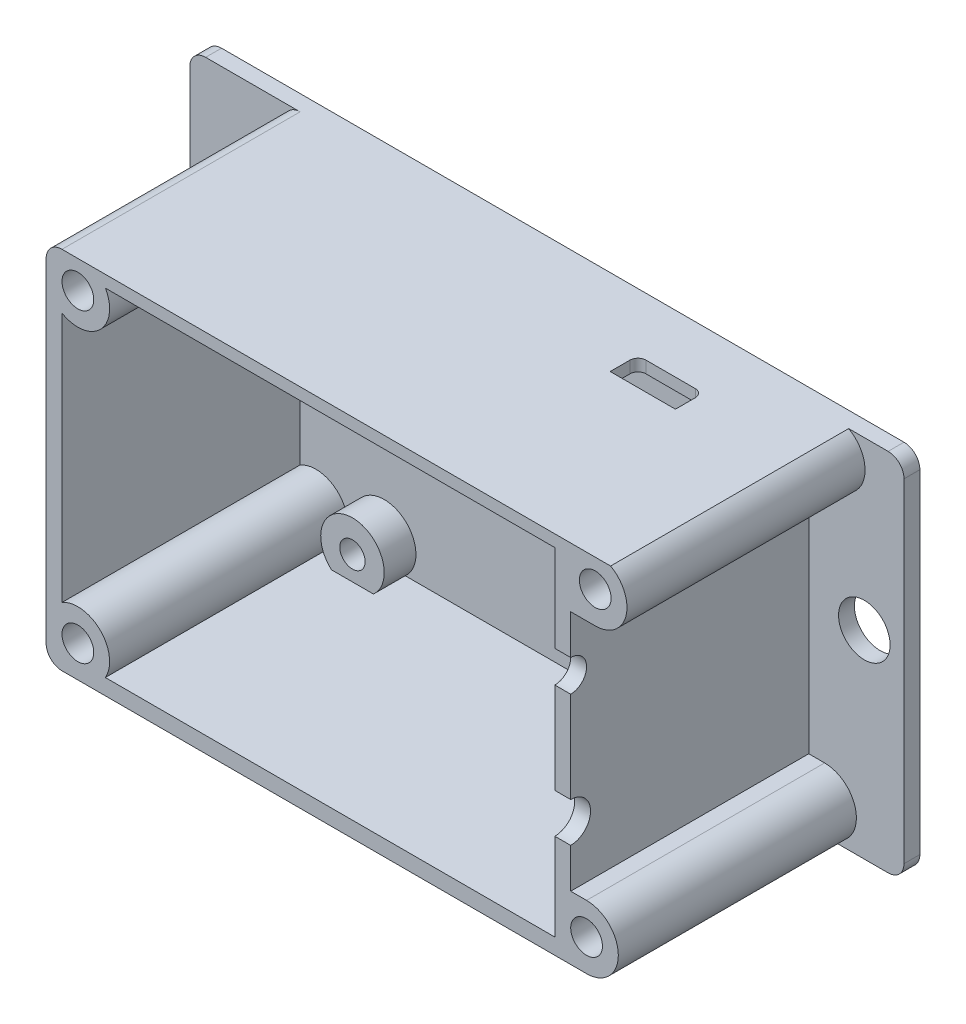
from build123d import *

# Parameters (mm, degrees)
SKETCH_2_R          = 3.25
EXTRUDE_1_DEPTH     = 2
SKETCH_2_3_R        = 2
EXTRUDE_2_DEPTH     = 30
SKETCH_2_4_R        = 1.6
EXTRUDE_3_DEPTH     = 4
CUT_EXTRUDE_1_REACH = 95.984
SKETCH_3_R          = 2.5
SKETCH_3_R_2        = 2
CUT_EXTRUDE_2_REACH = 88.236


with BuildPart() as part:
    # 草图2 → 凸台-拉伸1 (new body)
    with BuildSketch(Plane.XY):
        with BuildLine():
            ThreePointArc((-20.5, 43.00095784), (-21.914213562, 42.415171403), (-22.5, 41.00095784))
            Line((-22.5, 41.00095784), (-22.5, -1))
            ThreePointArc((-22.5, -1), (-21.914213562, -2.414213562), (-20.5, -3))
            Line((-20.5, -3), (65.5, -3))
            ThreePointArc((65.5, -3), (66.914213562, -2.414213562), (67.5, -1))
            Line((67.5, -1), (67.5, 41.00095784))
            ThreePointArc((67.5, 41.00095784), (66.914213562, 42.415171403), (65.5, 43.00095784))
            Line((65.5, 43.00095784), (-20.5, 43.00095784))
        make_face()
        with Locations((-17.5, 22)):
            Circle(SKETCH_2_R, mode=Mode.SUBTRACT)
        with Locations((62.5, 22)):
            Circle(SKETCH_2_R, mode=Mode.SUBTRACT)
    extrude(amount=-EXTRUDE_1_DEPTH)

    # 草图2<3> → 凸台-拉伸2 (add)
    with BuildSketch(Plane.XY):
        with BuildLine():
            ThreePointArc((-10.601500464, -1), (-10.015714027, -2.414213562), (-8.601500464, -3))
            Line((-8.601500464, -3), (57.5, -3))
            ThreePointArc((57.5, -3), (61.5, 1), (57.5, 5))
            Line((57.5, 5), (55.5, 5))
            Line((55.5, 5), (55.5, 35.50095784))
            Line((55.5, 35.50095784), (58.590729836, 35.50095784))
            ThreePointArc((58.590729836, 35.50095784), (62.463713182, 38.50095784), (60.527221509, 43.00095784))
            Line((60.527221509, 43.00095784), (-8.601500464, 43.00095784))
            ThreePointArc((-8.601500464, 43.00095784), (-10.015714027, 42.415171403), (-10.601500464, 41.00095784))
            Line((-10.601500464, 41.00095784), (-10.601500464, -1))
        make_face()
        with Locations((-6.601500464, 1)):
            Circle(SKETCH_2_3_R, mode=Mode.SUBTRACT)
        with BuildLine():
            ThreePointArc((-3.137398849, -1), (-3.77307334, 3.828427125), (-8.601500464, 4.464101615))
            Line((-8.601500464, 4.464101615), (-8.601500464, 36.036856225))
            ThreePointArc((-8.601500464, 36.036856225), (-3.77307334, 36.672530716), (-3.137398849, 41.50095784))
            Line((-3.137398849, 41.50095784), (53.5, 41.50095784))
            Line((53.5, 41.50095784), (53.5, -1))
            Line((53.5, -1), (-3.137398849, -1))
        make_face(mode=Mode.SUBTRACT)
        with Locations((-6.601500464, 39.50095784)):
            Circle(SKETCH_2_3_R, mode=Mode.SUBTRACT)
        with Locations((58.590729836, 39.50095784)):
            Circle(SKETCH_2_3_R, mode=Mode.SUBTRACT)
        with Locations((57.5, 1)):
            Circle(SKETCH_2_3_R, mode=Mode.SUBTRACT)
    extrude(amount=EXTRUDE_2_DEPTH)

    # 草图2<4> → 凸台-拉伸3 (add)
    # profile 1 of 4: a face of its own
    with BuildSketch(Plane.XY):
        with BuildLine():
            ThreePointArc((4.645751311, -1), (2, 6), (-0.645751311, -1))
            Line((-0.645751311, -1), (4.645751311, -1))
        make_face()
        with Locations((2, 2)):
            Circle(SKETCH_2_4_R, mode=Mode.SUBTRACT)
    # profile 2 of 4: a face of its own
    with BuildSketch(Plane.XY):
        with BuildLine():
            ThreePointArc((53.5, 4.645751311), (47.671572875, 4.828427125), (47.854248689, -1))
            Line((47.854248689, -1), (53.5, -1))
            Line((53.5, -1), (53.5, 4.645751311))
        make_face()
        with Locations((50.5, 2)):
            Circle(SKETCH_2_4_R, mode=Mode.SUBTRACT)
    # profile 3 of 4: a face of its own
    with BuildSketch(Plane.XY):
        with BuildLine():
            Line((4.872781496, 41.50095784), (-0.872781496, 41.50095784))
            ThreePointArc((-0.872781496, 41.50095784), (2, 35.99904216), (4.872781496, 41.50095784))
        make_face()
        with Locations((2, 39.5)):
            Circle(SKETCH_2_4_R, mode=Mode.SUBTRACT)
    # profile 4 of 4: a face of its own
    with BuildSketch(Plane.XY):
        with BuildLine():
            ThreePointArc((47.627218504, 41.50095784), (48.596140902, 36.56196897), (53.5, 37.695365466))
            Line((53.5, 37.695365466), (53.5, 41.50095784))
            Line((53.5, 41.50095784), (47.627218504, 41.50095784))
        make_face()
        with Locations((50.5, 39.5)):
            Circle(SKETCH_2_4_R, mode=Mode.SUBTRACT)
    extrude(amount=EXTRUDE_3_DEPTH)

    # 草图3 → 切除-拉伸1 (cut, up to next)
    with BuildSketch(Plane(origin=(55.5, 0, 0), x_dir=(0, 0, -1), z_dir=(1, 0, 0)), mode=Mode.PRIVATE) as cut_extrude_1_sk1:
        with Locations((-30, 12.50095784)):
            Circle(SKETCH_3_R)
    cut_extrude_1_tool1 = extrude(cut_extrude_1_sk1.sketch, amount=-CUT_EXTRUDE_1_REACH, mode=Mode.PRIVATE) & part.part
    # 草图3 → 切除-拉伸1 (cut, up to next)
    with BuildSketch(Plane(origin=(55.5, 0, 0), x_dir=(0, 0, -1), z_dir=(1, 0, 0)), mode=Mode.PRIVATE) as cut_extrude_1_sk2:
        with Locations((-30, 28.50095784)):
            Circle(SKETCH_3_R_2)
    cut_extrude_1_tool2 = extrude(cut_extrude_1_sk2.sketch, amount=-CUT_EXTRUDE_1_REACH, mode=Mode.PRIVATE) & part.part
    add(cut_extrude_1_tool1.solids().sort_by_distance((55.5, 12.500958, 30))[0], mode=Mode.SUBTRACT)
    add(cut_extrude_1_tool2.solids().sort_by_distance((55.5, 28.500958, 30))[0], mode=Mode.SUBTRACT)

    # 草图5 → 切除-拉伸2 (cut, up to next)
    with BuildSketch(Plane.XZ.offset(-41.50095784), mode=Mode.PRIVATE) as cut_extrude_2_sk1:
        with BuildLine():
            Line((39.27567, 8.8), (47.49867, 8.8))
            Line((47.49867, 8.8), (47.49867, 6.3))
            ThreePointArc((47.49867, 6.3), (47.205776781, 5.592893219), (46.49867, 5.3))
            Line((46.49867, 5.3), (40.27567, 5.3))
            ThreePointArc((40.27567, 5.3), (39.568563219, 5.592893219), (39.27567, 6.3))
            Line((39.27567, 6.3), (39.27567, 8.8))
        make_face()
    cut_extrude_2_tool1 = extrude(cut_extrude_2_sk1.sketch, amount=-CUT_EXTRUDE_2_REACH, mode=Mode.PRIVATE) & part.part
    add(cut_extrude_2_tool1.solids().sort_by_distance((43.38717, 41.500958, 7.073111))[0], mode=Mode.SUBTRACT)


solid = part.part
